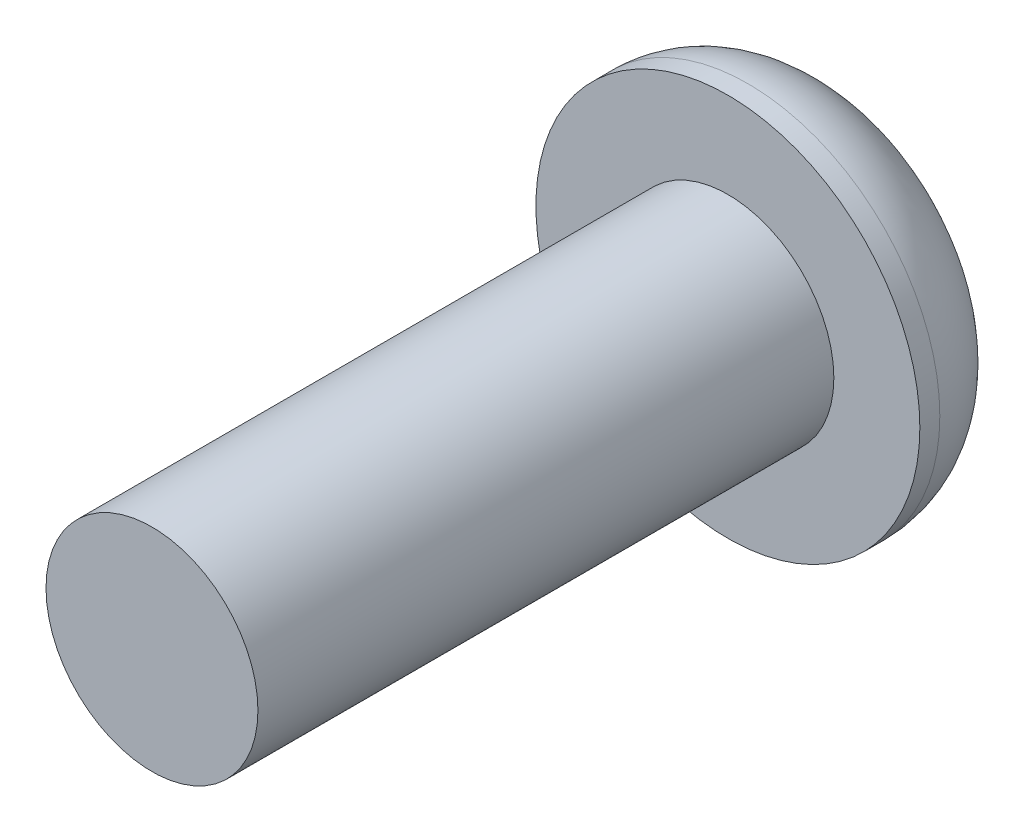
from build123d import *

# Parameters (mm, degrees)
SKETCH1_R      = 3.175
EXTRUDE1_DEPTH = 1.8542
FILLET1_R      = 1.524
SKETCH2_R      = 1.7526
EXTRUDE2_DEPTH = 9.525
EXTRUDE3_DEPTH = 1.016


with BuildPart() as part:
    # Sketch1 → Extrude1 (new body)
    with BuildSketch(Plane.XY):
        Circle(SKETCH1_R)
    extrude(amount=EXTRUDE1_DEPTH)

    # Fillet1
    fillet1_edges = [part.edges().sort_by_distance(p)[0] for p in [
        (-3.175, 0, 0),
    ]]
    fillet(fillet1_edges, radius=FILLET1_R)

    # Sketch2 → Extrude2 (add)
    with BuildSketch(Plane.XY.offset(1.8542)):
        Circle(SKETCH2_R)
    extrude(amount=EXTRUDE2_DEPTH)

    # Sketch3 → Extrude3 (cut)
    with BuildSketch(Plane(origin=(0, 0, 0), x_dir=(-1, 0, 0), z_dir=(0, 0, -1))):
        Polygon((0.59085384, 0.981566666), (-0.554634748, 1.002477769), (-1.145488588, 0.020911103), (-0.59085384, -0.981566666), (0.554634748, -1.002477769), (1.145488588, -0.020911103), align=None)
    extrude(amount=-EXTRUDE3_DEPTH, mode=Mode.SUBTRACT)


solid = part.part
